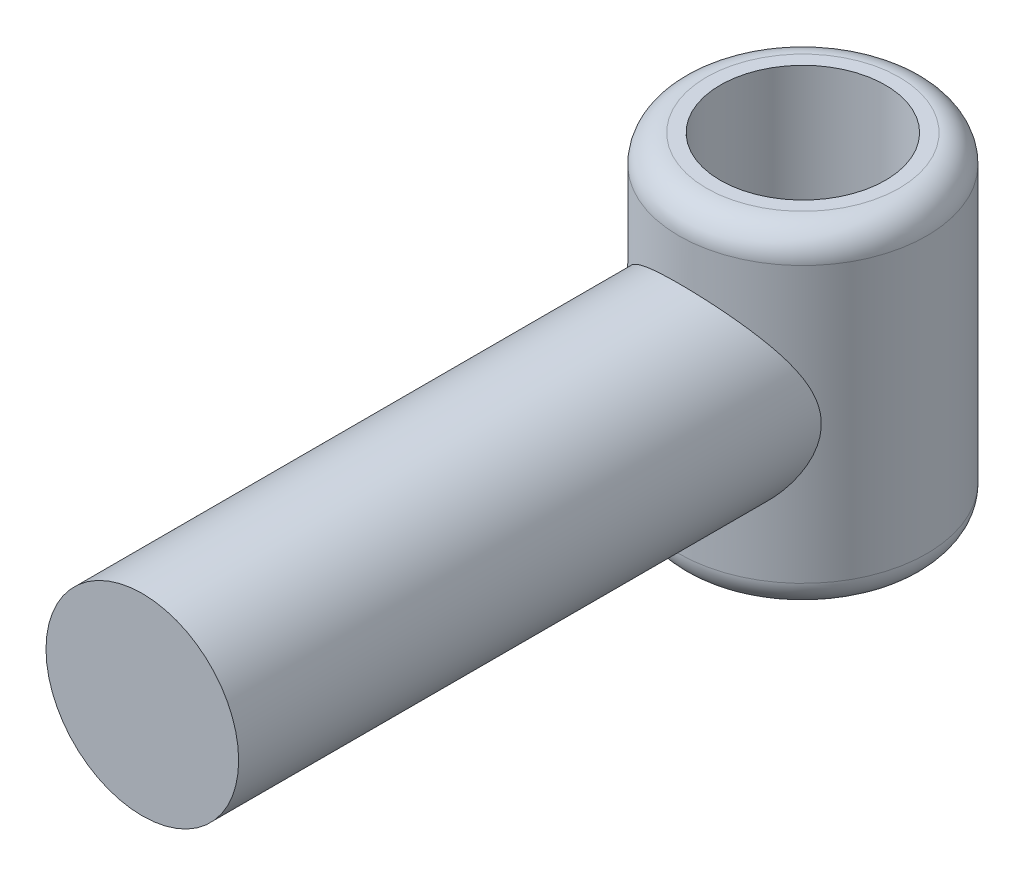
from build123d import *

# Parameters (mm, degrees)
SKETCH2_R                = 22.225
BOSS_EXTRUDE1_DEPTH      = 152.4
BOSS_EXTRUDE2_DEPTH      = 38.1
BOSS_EXTRUDE2_DEPTH_BACK = 38.1
SKETCH3_R                = 28.575
SKETCH4_R                = 19.05
CUT_EXTRUDE1_DEPTH       = 98.298
FILLET1_R                = 6.35


with BuildPart() as part:
    # Sketch2 → Boss-Extrude1 (new body)
    with BuildSketch(Plane.XY):
        Circle(SKETCH2_R)
    extrude(amount=BOSS_EXTRUDE1_DEPTH)

    # Sketch3 → Boss-Extrude2 (add, two sides: drawn at the far end of the back side and taken through both)
    with BuildSketch(Plane(origin=(0, 0, 0), x_dir=(1, 0, 0), z_dir=(0, 1, 0)).offset(-BOSS_EXTRUDE2_DEPTH_BACK)):
        Circle(SKETCH3_R)
    extrude(amount=BOSS_EXTRUDE2_DEPTH + BOSS_EXTRUDE2_DEPTH_BACK)

    # Sketch4 → Cut-Extrude1 (cut)
    with BuildSketch(Plane(origin=(0, 38.1, 0), x_dir=(1, 0, 0), z_dir=(0, 1, 0))):
        Circle(SKETCH4_R)
    extrude(amount=-CUT_EXTRUDE1_DEPTH, mode=Mode.SUBTRACT)

    # Fillet1
    fillet1_edges = [part.edges().sort_by_distance(p)[0] for p in [
        (-28.575, -38.1, 0),
        (-28.575, 38.1, 0),
    ]]
    fillet(fillet1_edges, radius=FILLET1_R)


solid = part.part
